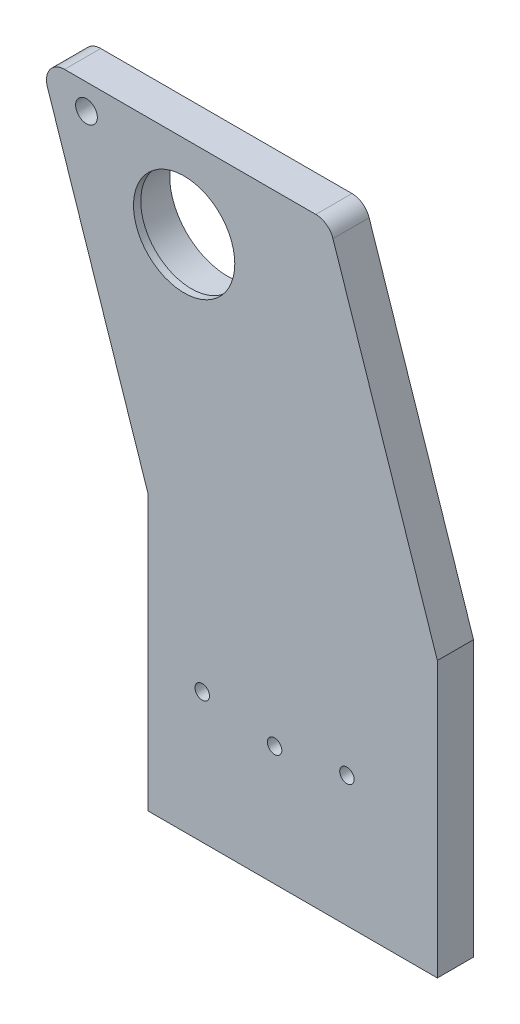
from build123d import *

# Parameters (mm, degrees)
SKETCH1_R           = 16
BOSS_EXTRUDE1_DEPTH = 10
SKETCH2_R           = 18
SKETCH2_R_2         = 16
BOSS_EXTRUDE2_DEPTH = 12
SKETCH3_R           = 2
CUT_EXTRUDE1_DEPTH  = 10
CUT_EXTRUDE2_REACH  = 14
SKETCH4_R           = 3
CUT_EXTRUDE3_REACH  = 12
SKETCH5_R           = 2
FILLET1_R           = 5
BOSS_EXTRUDE3_START = -2
SKETCH7_R           = 16
SKETCH7_R_2         = 14
BOSS_EXTRUDE3_DEPTH = 2


with BuildPart() as part:
    # Sketch1 → Boss-Extrude1 (new body)
    with BuildSketch(Plane.XY):
        Polygon((-40, 83), (-70, 83), (-40, -7), (-40, -83), (40, -83), (40, -7), (10, 83), align=None)
        with Locations((-30, 60)):
            Circle(SKETCH1_R, mode=Mode.SUBTRACT)
    extrude(amount=BOSS_EXTRUDE1_DEPTH)

    # Sketch2 → Boss-Extrude2 (add)
    with BuildSketch(Plane.XY.offset(10)):
        with Locations((-30, 60)):
            Circle(SKETCH2_R)
        with Locations((-30, 60)):
            Circle(SKETCH2_R_2, mode=Mode.SUBTRACT)
    extrude(amount=-BOSS_EXTRUDE2_DEPTH)

    # Sketch3 → Cut-Extrude1 (cut)
    with BuildSketch(Plane.XY.offset(10)):
        with Locations((-25, -47)):
            Circle(SKETCH3_R)
        with Locations((15, -47)):
            Circle(SKETCH3_R)
    extrude(amount=-CUT_EXTRUDE1_DEPTH, mode=Mode.SUBTRACT)

    # Sketch4 → Cut-Extrude2 (cut, up to next)
    with BuildSketch(Plane.XY.offset(10), mode=Mode.PRIVATE) as cut_extrude2_sk1:
        with Locations((-57, 76)):
            Circle(SKETCH4_R)
    cut_extrude2_tool1 = extrude(cut_extrude2_sk1.sketch, amount=-CUT_EXTRUDE2_REACH, mode=Mode.PRIVATE) & part.part
    add(cut_extrude2_tool1.solids().sort_by_distance((-57, 76, 10))[0], mode=Mode.SUBTRACT)

    # Sketch5 → Cut-Extrude3 (cut, up to next)
    with BuildSketch(Plane(origin=(0, 0, 0), x_dir=(-1, 0, 0), z_dir=(0, 0, -1)), mode=Mode.PRIVATE) as cut_extrude3_sk1:
        with Locations((5, -50)):
            Circle(SKETCH5_R)
    cut_extrude3_tool1 = extrude(cut_extrude3_sk1.sketch, amount=-CUT_EXTRUDE3_REACH, mode=Mode.PRIVATE) & part.part
    add(cut_extrude3_tool1.solids().sort_by_distance((-5, -50, 0))[0], mode=Mode.SUBTRACT)

    # Fillet1
    fillet1_edges = [part.edges().sort_by_distance(p)[0] for p in [
        (-70, 83, 5),
        (10, 83, 5),
    ]]
    fillet(fillet1_edges, radius=FILLET1_R)

    # Sketch7 → Boss-Extrude3 (add)
    with BuildSketch(Plane.XY.offset(10).offset(BOSS_EXTRUDE3_START)):
        with Locations((-30, 60)):
            Circle(SKETCH7_R)
        with Locations((-30, 60)):
            Circle(SKETCH7_R_2, mode=Mode.SUBTRACT)
    extrude(amount=BOSS_EXTRUDE3_DEPTH)


solid = part.part
